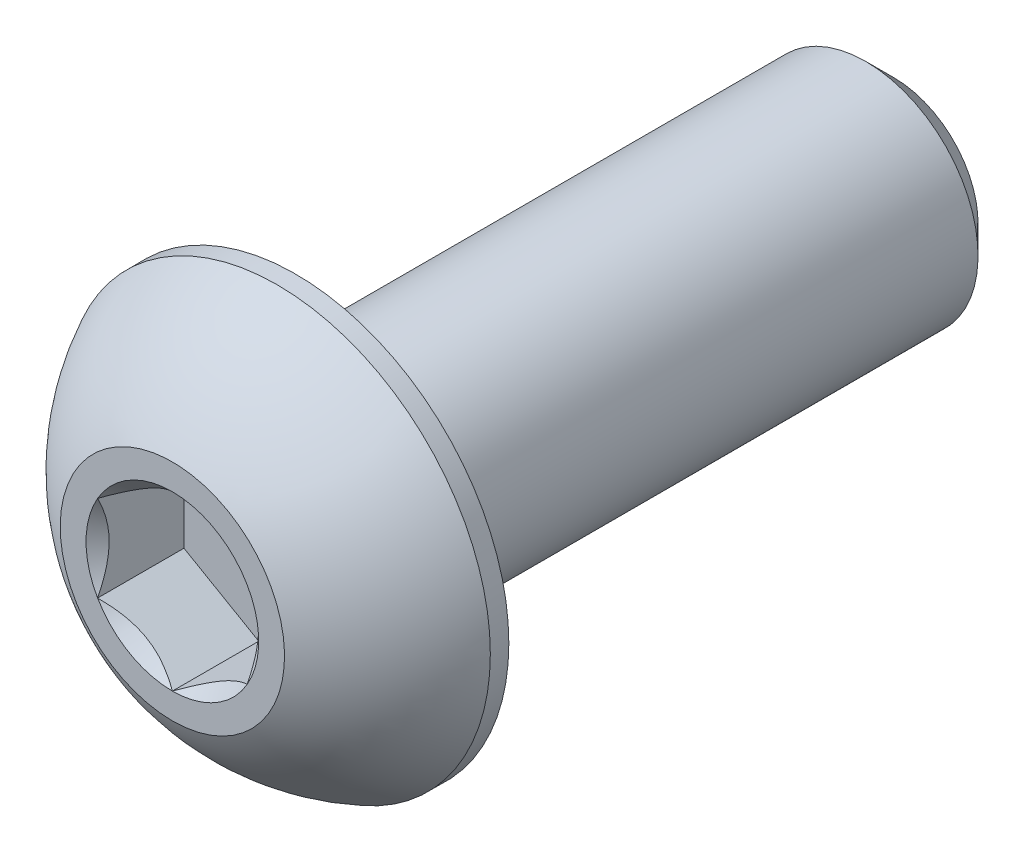
from build123d import *

# Parameters (mm, degrees)
SKETCH1_W          = 8
SKETCH1_H          = 1.5
CHAMFER1_SIZE      = 0.375
CUT_EXTRUDE2_DEPTH = 1.155


with BuildPart() as part:
    # Sketch1 → Revolve1 (revolve)
    with BuildSketch(Plane(origin=(0, 0, 0), x_dir=(0, 0, -1), z_dir=(1, 0, 0))):
        with Locations((5.65, 0.75)):
            Rectangle(SKETCH1_W, SKETCH1_H)
    revolve(axis=Axis((0, 0, -9.65), (0, 0, 1)))

    # Chamfer1
    chamfer1_edges = [part.edges().sort_by_distance(p)[0] for p in [
        (0, -1.5, -9.65),
    ]]
    chamfer(chamfer1_edges, length=CHAMFER1_SIZE)

    # Sketch7 → Revolve2 (revolve)
    with BuildSketch(Plane(origin=(0, 0, 0), x_dir=(0, 0, -1), z_dir=(1, 0, 0))):
        with BuildLine():
            Line((1.4025, 2.85), (1.65, 2.85))
            Line((1.65, 2.85), (1.65, 0))
            Line((1.65, 0), (0, 0))
            Line((0, 0), (0, 1.5))
            ThreePointArc((0, 1.5), (0.59512511, 2.285251969), (1.4025, 2.85))
        make_face()
    revolve(axis=Axis((0, 0, 0), (0, 0, -1)))

    # Sketch5 → Cut-Extrude2 (cut)
    with BuildSketch(Plane.XY):
        Polygon((1, -0.577350269), (1, 0.577350269), (0, 1.154700538), (-1, 0.577350269), (-1, -0.577350269), (0, -1.154700538), align=None)
    extrude(amount=-CUT_EXTRUDE2_DEPTH, mode=Mode.SUBTRACT)

    # Cut-Extrude3 cone 1 section (through the dimple's axis) → Cut-Extrude3 (revolve, cut)
    with BuildSketch(Plane(origin=(0, 0, 0), x_dir=(0, -1, 0), z_dir=(1, 0, 0))):
        Polygon((0, 0), (1.154700538, 0), (0, 1.154700538), align=None)
    revolve(axis=Axis((0, 0, 0), (0, 0, -1)), mode=Mode.SUBTRACT)


solid = part.part
